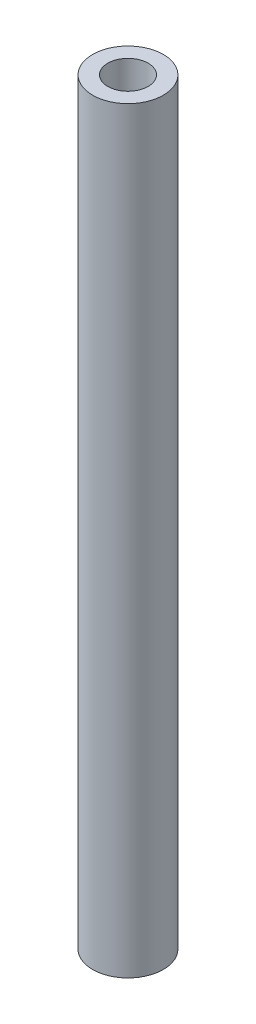
from build123d import *

# Parameters (mm, degrees)
ESBO_O1_W = 1.5
ESBO_O1_H = 75


with BuildPart() as part:
    # Esboço1 → Revolução1 (revolve)
    with BuildSketch(Plane(origin=(0, 0, 0), x_dir=(-1, 0, 0), z_dir=(0, 0, -1))):
        with Locations((53.96460554, -37.5)):
            Rectangle(ESBO_O1_W, ESBO_O1_H)
    revolve(axis=Axis((-56.71460554, -75, 0), (0, 1, 0)))


solid = part.part
